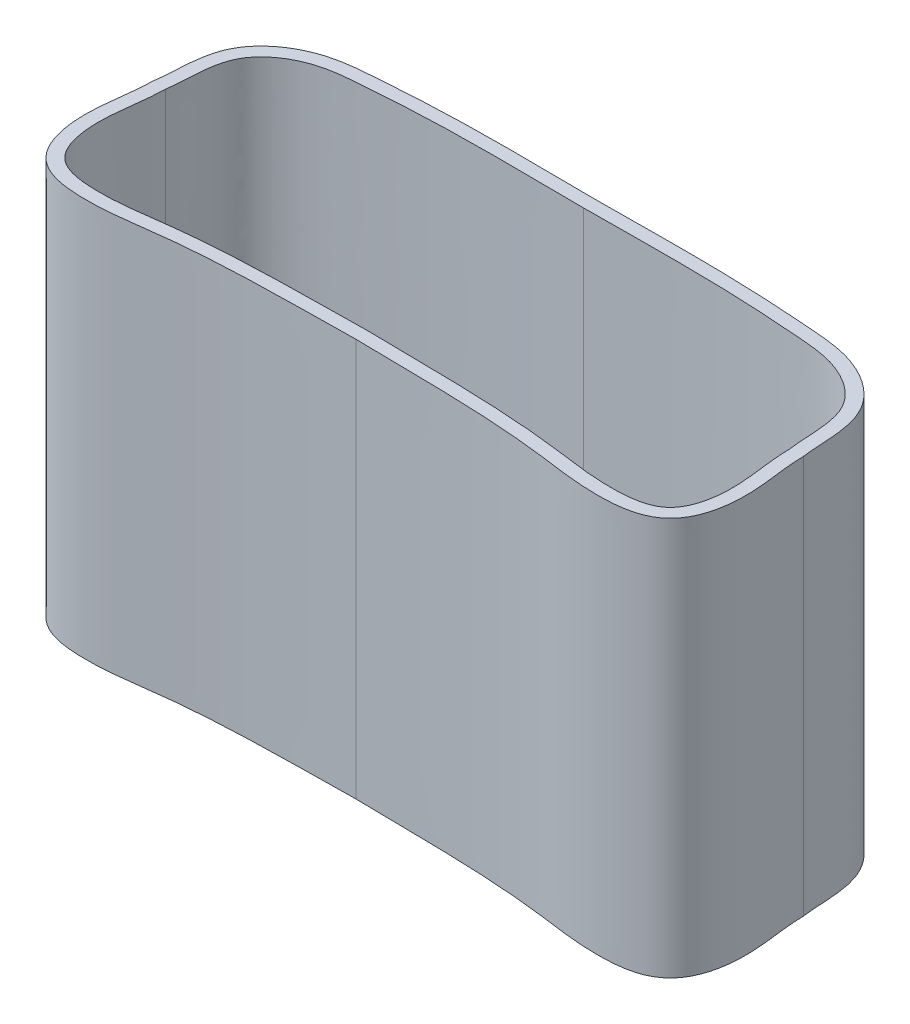
from build123d import *

# Parameters (mm, degrees)
Y_KSEKLIK_EKSTR_ZYON1_DEPTH = 60
Y_KSEKLIK_EKSTR_ZYON2_DEPTH = 3


with BuildPart() as part:
    # Çizim1 → Yükseklik-Ekstrüzyon1 (new body)
    with BuildSketch(Plane(origin=(0, 0, 0), x_dir=(1, 0, 0), z_dir=(0, 1, 0))):
        with BuildLine():
            add(Edge.make_bspline(
                [(-26.970898007, -3.863302647), (-26.961111238, -3.79832753), (-26.940514451, -3.663479453), (-26.908650018, -3.432794299), (-26.855769615, -2.990956505), (-26.773803233, -2.06068722), (-26.695412617, -0.5797462), (-26.572044258, 1.342358929), (-26.29879594, 3.354154668), (-25.74429138, 5.401513801), (-24.686909281, 7.408713935), (-23.232005387, 9.059306715), (-20.958998606, 10.853261454), (-17.678240908, 12.397082823), (-13.723319496, 13.107903004), (-10.167248595, 13.347990346), (-6.591800716, 13.613621395), (-2.997016963, 13.811706505), (1.797578973, 13.990401922), (7.770091472, 14.069250179), (14.915818339, 14.03274079), (19.654663039, 13.983231028), (22.027252434, 13.967774119)],
                knots=[-0.002603107, -0.002603107, -0.002603107, -0.002603107, 0.001312416, 0.005227939, 0.013058984, 0.028721076, 0.060045259, 0.091369441, 0.122693624, 0.154017807, 0.18534199, 0.216666172, 0.247990355, 0.310638721, 0.373287086, 0.435935452, 0.498583817, 0.561232183, 0.623880548, 0.749177279, 0.87447401, 0.999770741, 0.999770741, 0.999770741, 0.999770741], degree=3))
            add(Edge.make_bspline(
                [(22.027252434, 13.967774119), (24.399841829, 13.983231028), (29.138686528, 14.03274079), (36.284413396, 14.069250179), (42.256925894, 13.990401922), (47.05152183, 13.811706505), (50.646305584, 13.613621395), (54.221753463, 13.347990346), (57.777824364, 13.107903004), (61.732745775, 12.397082823), (65.013503474, 10.853261454), (67.286510254, 9.059306715), (68.741414148, 7.408713935), (69.798796248, 5.401513801), (70.353300808, 3.354154668), (70.626549125, 1.342358929), (70.749917484, -0.5797462), (70.8283081, -2.06068722), (70.910274482, -2.990956505), (70.963154886, -3.432794299), (70.995019319, -3.663479453), (71.015616105, -3.79832753), (71.025402875, -3.863302647)],
                knots=[-0.002603107, -0.002603107, -0.002603107, -0.002603107, 0.122693624, 0.247990355, 0.373287086, 0.435935452, 0.498583817, 0.561232183, 0.623880548, 0.686528914, 0.749177279, 0.780501462, 0.811825645, 0.843149827, 0.87447401, 0.905798193, 0.937122376, 0.968446558, 0.98410865, 0.991939695, 0.995855218, 0.999770741, 0.999770741, 0.999770741, 0.999770741], degree=3))
            add(Edge.make_bspline(
                [(71.025402875, -3.863302647), (71.027447765, -4.028816444), (71.032524159, -4.364432015), (71.057161293, -4.998619829), (71.12976779, -6.10764478), (71.368210023, -8.290308489), (71.813451753, -11.491001265), (71.837091858, -15.190160573), (71.202453065, -18.391266216), (70.395807949, -20.326612065), (69.378765227, -21.733075846), (68.033492138, -22.968289807), (66.090451412, -23.872659179), (63.704214477, -24.345354377), (61.393917391, -24.48088566), (59.233139242, -24.462658569), (56.453282735, -24.282769986), (53.170079378, -23.860055473), (49.415458669, -23.357705909), (44.290793655, -22.889288028), (37.741693389, -22.557594682), (31.139454307, -22.437137868), (25.896327818, -22.374349869), (23.320716055, -22.339688809), (22.027252434, -22.317338744)],
                knots=[-0.002027927, -0.002027927, -0.002027927, -0.002027927, 0.005796012, 0.013619951, 0.02926783, 0.060563587, 0.123155101, 0.185746614, 0.217042371, 0.248338128, 0.263986007, 0.279633885, 0.310929642, 0.342225399, 0.373521156, 0.404816913, 0.43611267, 0.498704184, 0.561295697, 0.623887211, 0.749070239, 0.874253267, 0.93684478, 0.999436294, 0.999436294, 0.999436294, 0.999436294], degree=3))
            add(Edge.make_bspline(
                [(22.027252434, -22.317338744), (20.733788813, -22.339688809), (18.158177049, -22.374349869), (12.91505056, -22.437137868), (6.312811478, -22.557594682), (-0.236288787, -22.889288028), (-5.360953801, -23.357705909), (-9.115574511, -23.860055473), (-12.398777867, -24.282769986), (-15.178634374, -24.462658569), (-17.339412523, -24.48088566), (-19.64970961, -24.345354377), (-22.035946544, -23.872659179), (-23.97898727, -22.968289807), (-25.324260359, -21.733075846), (-26.341303082, -20.326612065), (-27.147948197, -18.391266216), (-27.78258699, -15.190160573), (-27.758946886, -11.491001265), (-27.313705155, -8.290308489), (-27.075262923, -6.10764478), (-27.002656425, -4.998619829), (-26.978019292, -4.364432015), (-26.972942898, -4.028816444), (-26.970898007, -3.863302647)],
                knots=[-0.002027927, -0.002027927, -0.002027927, -0.002027927, 0.060563587, 0.123155101, 0.248338128, 0.373521156, 0.43611267, 0.498704184, 0.561295697, 0.592591454, 0.623887211, 0.655182968, 0.686478725, 0.717774482, 0.733422361, 0.749070239, 0.780365996, 0.811661753, 0.874253267, 0.93684478, 0.968140537, 0.983788416, 0.991612355, 0.999436294, 0.999436294, 0.999436294, 0.999436294], degree=3))
        make_face()
        with BuildLine():
            add(Edge.make_bspline(
                [(-24.972747566, -4.0253606), (-24.526358955, -1.061752174), (-25.253926096, 5.881879611), (-17.667513986, 10.721214232), (-10.317198482, 11.355723769), (2.660643875, 12.245739731), (13.737328433, 12.021619781), (22.027252434, 11.96773177)],
                knots=[0, 0, 0, 0, 0.17038957, 0.314818436, 0.415070115, 0.562400147, 1, 1, 1, 1], degree=3))
            add(Edge.make_bspline(
                [(69.027252434, -4.0253606), (68.580863823, -1.061752174), (69.308430963, 5.881879611), (61.722018853, 10.721214232), (54.37170335, 11.355723769), (41.393860993, 12.245739731), (30.317176435, 12.021619781), (22.027252434, 11.96773177)],
                knots=[0, 0, 0, 0, 0.17038957, 0.314818436, 0.415070115, 0.562400147, 1, 1, 1, 1], degree=3))
            add(Edge.make_bspline(
                [(69.027252434, -4.0253606), (69.073574705, -7.774692699), (70.537868808, -12.77573667), (68.506640847, -21.747382309), (59.711458497, -22.910863901), (45.184719049, -20.355064178), (31.437040426, -20.480284225), (22.027252434, -20.317039)],
                knots=[0, 0, 0, 0, 0.166072658, 0.272844916, 0.372685226, 0.539422899, 1, 1, 1, 1], degree=3))
            add(Edge.make_bspline(
                [(-24.972747566, -4.0253606), (-25.019069838, -7.774692699), (-26.48336394, -12.77573667), (-24.452135979, -21.747382309), (-15.65695363, -22.910863901), (-1.130214182, -20.355064178), (12.617464441, -20.480284225), (22.027252434, -20.317039)],
                knots=[0, 0, 0, 0, 0.166072658, 0.272844916, 0.372685226, 0.539422899, 1, 1, 1, 1], degree=3))
        make_face(mode=Mode.SUBTRACT)
    extrude(amount=Y_KSEKLIK_EKSTR_ZYON1_DEPTH)

    # Çizim4 → Yükseklik-Ekstrüzyon2 (add)
    with BuildSketch(Plane.XZ):
        with BuildLine():
            add(Edge.make_bspline(
                [(-26.970898007, 3.863302647), (-26.961111238, 3.79832753), (-26.940514451, 3.663479453), (-26.908650018, 3.432794299), (-26.855769615, 2.990956505), (-26.773803233, 2.06068722), (-26.695412617, 0.5797462), (-26.572044258, -1.342358929), (-26.29879594, -3.354154668), (-25.74429138, -5.401513801), (-24.686909281, -7.408713935), (-23.232005387, -9.059306715), (-20.958998606, -10.853261454), (-17.678240908, -12.397082823), (-13.723319496, -13.107903004), (-10.167248595, -13.347990346), (-6.591800716, -13.613621395), (-2.997016963, -13.811706505), (1.797578973, -13.990401922), (7.770091472, -14.069250179), (14.915818339, -14.03274079), (19.654663039, -13.983231028), (22.027252434, -13.967774119)],
                knots=[-0.002603107, -0.002603107, -0.002603107, -0.002603107, 0.001312416, 0.005227939, 0.013058984, 0.028721076, 0.060045259, 0.091369441, 0.122693624, 0.154017807, 0.18534199, 0.216666172, 0.247990355, 0.310638721, 0.373287086, 0.435935452, 0.498583817, 0.561232183, 0.623880548, 0.749177279, 0.87447401, 0.999770741, 0.999770741, 0.999770741, 0.999770741], degree=3))
            add(Edge.make_bspline(
                [(22.027252434, -13.967774119), (24.399841829, -13.983231028), (29.138686528, -14.03274079), (36.284413396, -14.069250179), (42.256925894, -13.990401922), (47.05152183, -13.811706505), (50.646305584, -13.613621395), (54.221753463, -13.347990346), (57.777824364, -13.107903004), (61.732745775, -12.397082823), (65.013503474, -10.853261454), (67.286510254, -9.059306715), (68.741414148, -7.408713935), (69.798796248, -5.401513801), (70.353300808, -3.354154668), (70.626549125, -1.342358929), (70.749917484, 0.5797462), (70.8283081, 2.06068722), (70.910274482, 2.990956505), (70.963154886, 3.432794299), (70.995019319, 3.663479453), (71.015616105, 3.79832753), (71.025402875, 3.863302647)],
                knots=[-0.002603107, -0.002603107, -0.002603107, -0.002603107, 0.122693624, 0.247990355, 0.373287086, 0.435935452, 0.498583817, 0.561232183, 0.623880548, 0.686528914, 0.749177279, 0.780501462, 0.811825645, 0.843149827, 0.87447401, 0.905798193, 0.937122376, 0.968446558, 0.98410865, 0.991939695, 0.995855218, 0.999770741, 0.999770741, 0.999770741, 0.999770741], degree=3))
            add(Edge.make_bspline(
                [(71.025402875, 3.863302647), (71.027447765, 4.028816444), (71.032524159, 4.364432015), (71.057161293, 4.998619829), (71.12976779, 6.10764478), (71.368210023, 8.290308489), (71.813451753, 11.491001265), (71.837091858, 15.190160573), (71.202453065, 18.391266216), (70.395807949, 20.326612065), (69.378765227, 21.733075846), (68.033492138, 22.968289807), (66.090451412, 23.872659179), (63.704214477, 24.345354377), (61.393917391, 24.48088566), (59.233139242, 24.462658569), (56.453282735, 24.282769986), (53.170079378, 23.860055473), (49.415458669, 23.357705909), (44.290793655, 22.889288028), (37.741693389, 22.557594682), (31.139454307, 22.437137868), (25.896327818, 22.374349869), (23.320716055, 22.339688809), (22.027252434, 22.317338744)],
                knots=[-0.002027927, -0.002027927, -0.002027927, -0.002027927, 0.005796012, 0.013619951, 0.02926783, 0.060563587, 0.123155101, 0.185746614, 0.217042371, 0.248338128, 0.263986007, 0.279633885, 0.310929642, 0.342225399, 0.373521156, 0.404816913, 0.43611267, 0.498704184, 0.561295697, 0.623887211, 0.749070239, 0.874253267, 0.93684478, 0.999436294, 0.999436294, 0.999436294, 0.999436294], degree=3))
            add(Edge.make_bspline(
                [(22.027252434, 22.317338744), (20.733788813, 22.339688809), (18.158177049, 22.374349869), (12.91505056, 22.437137868), (6.312811478, 22.557594682), (-0.236288787, 22.889288028), (-5.360953801, 23.357705909), (-9.115574511, 23.860055473), (-12.398777867, 24.282769986), (-15.178634374, 24.462658569), (-17.339412523, 24.48088566), (-19.64970961, 24.345354377), (-22.035946544, 23.872659179), (-23.97898727, 22.968289807), (-25.324260359, 21.733075846), (-26.341303082, 20.326612065), (-27.147948197, 18.391266216), (-27.78258699, 15.190160573), (-27.758946886, 11.491001265), (-27.313705155, 8.290308489), (-27.075262923, 6.10764478), (-27.002656425, 4.998619829), (-26.978019292, 4.364432015), (-26.972942898, 4.028816444), (-26.970898007, 3.863302647)],
                knots=[-0.002027927, -0.002027927, -0.002027927, -0.002027927, 0.060563587, 0.123155101, 0.248338128, 0.373521156, 0.43611267, 0.498704184, 0.561295697, 0.592591454, 0.623887211, 0.655182968, 0.686478725, 0.717774482, 0.733422361, 0.749070239, 0.780365996, 0.811661753, 0.874253267, 0.93684478, 0.968140537, 0.983788416, 0.991612355, 0.999436294, 0.999436294, 0.999436294, 0.999436294], degree=3))
        make_face()
    extrude(amount=-Y_KSEKLIK_EKSTR_ZYON2_DEPTH)


solid = part.part
